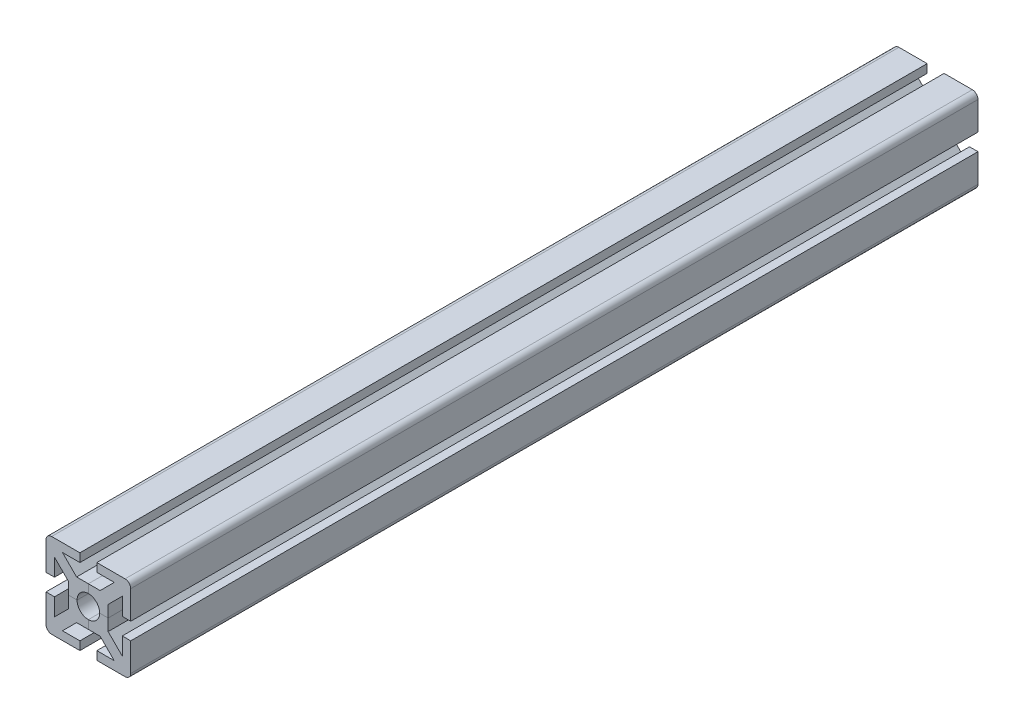
from build123d import *

# Parameters (mm, degrees)
SALIENTE_EXTRUIR1_DEPTH = 150
REDONDEO1_R             = 2
MATRIZC4_COUNT          = 4


with BuildPart() as part:
    # Croquis1 → Saliente-Extruir1 (new body, symmetric)
    with BuildSketch(Plane.XY):
        with BuildLine():
            Line((0, 4), (0, 7))
            Line((0, 7), (4.171572875, 7))
            Line((4.171572875, 7), (9.171572875, 12))
            Line((9.171572875, 12), (3, 12))
            Line((3, 12), (3, 15))
            Line((3, 15), (15, 15))
            Line((15, 15), (2.828427125, 2.828427125))
            ThreePointArc((2.828427125, 2.828427125), (1.530733729, 3.69551813), (0, 4))
        make_face()
    saliente_extruir1 = extrude(amount=SALIENTE_EXTRUIR1_DEPTH, both=True)

    # Simetría1: Saliente-Extruir1 across plane
    add(saliente_extruir1.mirror(Plane(origin=(2.828427125, 2.828427125, 150), x_dir=(0, 0, 1), z_dir=(-0.707106781, 0.707106781, 0))))

    # Redondeo1
    redondeo1_edges = [part.edges().sort_by_distance(p)[0] for p in [
        (15, 15, 0),
    ]]
    fillet(redondeo1_edges, radius=REDONDEO1_R)


with BuildPart() as matrizc4_1:
    # MatrizC4: pattern copy
    add(part.part.rotate(Axis((0, 0, 0), (0, 0, 1)), 1 * 360 / MATRIZC4_COUNT))


with BuildPart() as matrizc4_2:
    # MatrizC4: pattern copy
    add(part.part.rotate(Axis((0, 0, 0), (0, 0, 1)), 2 * 360 / MATRIZC4_COUNT))


with BuildPart() as matrizc4_3:
    # MatrizC4: pattern copy
    add(part.part.rotate(Axis((0, 0, 0), (0, 0, 1)), 3 * 360 / MATRIZC4_COUNT))


solid = Compound([part.part, matrizc4_1.part, matrizc4_2.part, matrizc4_3.part])
